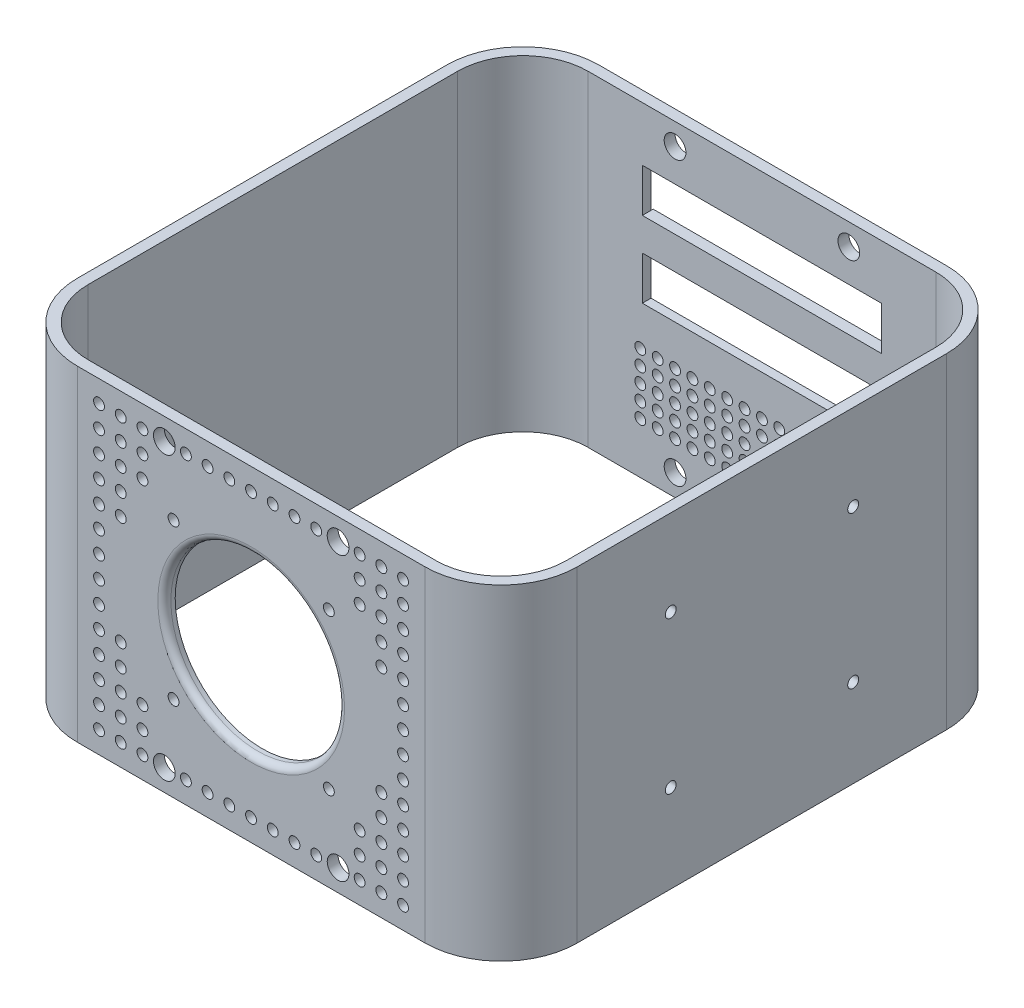
from build123d import *

# Parameters (mm, degrees)
BOSS_EXTRUDE1_DEPTH = 150
SKETCH11_R          = 2.5
CUT_EXTRUDE1_DEPTH  = 10
SKETCH12_R          = 5
CUT_EXTRUDE2_DEPTH  = 10
CUT_EXTRUDE3_START  = -10
SKETCH13_R          = 5
CUT_EXTRUDE3_DEPTH  = 10
SKETCH15_W          = 120.15
SKETCH15_H          = 65
CUT_EXTRUDE4_DEPTH  = 1
SKETCH15_3_W        = 110.15
SKETCH15_3_H        = 20
CUT_EXTRUDE5_DEPTH  = 10
SKETCH21_R          = 40
SKETCH21_R_2        = 2.5
CUT_EXTRUDE8_DEPTH  = 10
FILLET4_R           = 3
SKETCH27_R          = 2.5
CUT_EXTRUDE10_DEPTH = 10
SKETCH28_R          = 2.5
CUT_EXTRUDE13_DEPTH = 10


with BuildPart() as part:
    # Sketch1 → Boss-Extrude1 (new body)
    with BuildSketch(Plane(origin=(0, 0, 0), x_dir=(1, 0, 0), z_dir=(0, 1, 0))):
        with BuildLine():
            Line((-5, 30), (-5, 200.15))
            ThreePointArc((-5, 200.15), (5.251262658, 224.898737342), (30, 235.15))
            Line((30, 235.15), (190.15, 235.15))
            ThreePointArc((190.15, 235.15), (214.898737342, 224.898737342), (225.15, 200.15))
            Line((225.15, 200.15), (225.15, 30))
            ThreePointArc((225.15, 30), (214.898737342, 5.251262658), (190.15, -5))
            Line((190.15, -5), (30, -5))
            ThreePointArc((30, -5), (5.251262658, 5.251262658), (-5, 30))
        make_face()
        with BuildLine():
            Line((30, 0), (190.15, 0))
            ThreePointArc((190.15, 0), (211.363203436, 8.786796564), (220.15, 30))
            Line((220.15, 30), (220.15, 200.15))
            ThreePointArc((220.15, 200.15), (211.363203436, 221.363203436), (190.15, 230.15))
            Line((190.15, 230.15), (30, 230.15))
            ThreePointArc((30, 230.15), (8.786796564, 221.363203436), (0, 200.15))
            Line((0, 200.15), (0, 30))
            ThreePointArc((0, 30), (8.786796564, 8.786796564), (30, 0))
        make_face(mode=Mode.SUBTRACT)
    extrude(amount=BOSS_EXTRUDE1_DEPTH)

    # Sketch11 → Cut-Extrude1 (cut)
    with BuildSketch(Plane(origin=(225.15, 0, 0), x_dir=(0, 0, -1), z_dir=(1, 0, 0))):
        with Locations((73.075, 110.506208535)):
            Circle(SKETCH11_R)
        with Locations((73.075, 40.506208535)):
            Circle(SKETCH11_R)
        with Locations((157.075, 40.506208535)):
            Circle(SKETCH11_R)
        with Locations((157.075, 110.506208535)):
            Circle(SKETCH11_R)
    extrude(amount=-CUT_EXTRUDE1_DEPTH, mode=Mode.SUBTRACT)

    # Sketch12 → Cut-Extrude2 (cut)
    with BuildSketch(Plane(origin=(0, 0, -235.15), x_dir=(-1, 0, 0), z_dir=(0, 0, -1))):
        with Locations((-150.075, 140)):
            Circle(SKETCH12_R)
        with Locations((-70.075, 140)):
            Circle(SKETCH12_R)
        with Locations((-70.075, 10)):
            Circle(SKETCH12_R)
        with Locations((-150.075, 10)):
            Circle(SKETCH12_R)
    extrude(amount=-CUT_EXTRUDE2_DEPTH, mode=Mode.SUBTRACT)

    # Sketch13 → Cut-Extrude3 (cut)
    with BuildSketch(Plane.XY.offset(5).offset(CUT_EXTRUDE3_START)):
        with Locations((70.075, 140)):
            Circle(SKETCH13_R)
        with Locations((150.075, 140)):
            Circle(SKETCH13_R)
        with Locations((150.075, 10)):
            Circle(SKETCH13_R)
        with Locations((70.075, 10)):
            Circle(SKETCH13_R)
    extrude(amount=CUT_EXTRUDE3_DEPTH, mode=Mode.SUBTRACT)

    # Sketch15 → Cut-Extrude4 (cut)
    with BuildSketch(Plane(origin=(0, 0, -235.15), x_dir=(-1, 0, 0), z_dir=(0, 0, -1))):
        with Locations((-110.075, 97.5)):
            Rectangle(SKETCH15_W, SKETCH15_H)
        Polygon((-165.15, 105), (-165.15, 125), (-55, 125), (-55, 105), (-55, 90), (-55, 70), (-165.15, 70), (-165.15, 90), align=None, mode=Mode.SUBTRACT)
    extrude(amount=-CUT_EXTRUDE4_DEPTH, mode=Mode.SUBTRACT)

    # Sketch15_3 → Cut-Extrude5 (cut)
    with BuildSketch(Plane(origin=(0, 0, -235.15), x_dir=(-1, 0, 0), z_dir=(0, 0, -1))):
        with Locations((-110.075, 115)):
            Rectangle(SKETCH15_3_W, SKETCH15_3_H)
        with Locations((-110.075, 80)):
            Rectangle(SKETCH15_3_W, SKETCH15_3_H)
    extrude(amount=-CUT_EXTRUDE5_DEPTH, mode=Mode.SUBTRACT)

    # Sketch21 → Cut-Extrude8 (cut)
    with BuildSketch(Plane.XY.offset(5)):
        with Locations((110.075, 75)):
            Circle(SKETCH21_R)
        with Locations((74.325, 110.75)):
            Circle(SKETCH21_R_2)
        with Locations((145.825, 110.75)):
            Circle(SKETCH21_R_2)
        with Locations((145.825, 39.25)):
            Circle(SKETCH21_R_2)
        with Locations((74.325, 39.25)):
            Circle(SKETCH21_R_2)
    extrude(amount=-CUT_EXTRUDE8_DEPTH, mode=Mode.SUBTRACT)

    # Fillet4
    fillet4_edges = [part.edges().sort_by_distance(p)[0] for p in [
        (70.075, 75, 5),
    ]]
    fillet(fillet4_edges, radius=FILLET4_R)

    # Sketch27 → Cut-Extrude10 (cut)
    with BuildSketch(Plane(origin=(0, 0, -235.15), x_dir=(-1, 0, 0), z_dir=(0, 0, -1))):
        with Locations((-118.075, 37.5)):
            Circle(SKETCH27_R)
        with Locations((-126.075, 37.5)):
            Circle(SKETCH27_R)
        with Locations((-134.075, 37.5)):
            Circle(SKETCH27_R)
        with Locations((-142.075, 37.5)):
            Circle(SKETCH27_R)
        with Locations((-150.075, 37.5)):
            Circle(SKETCH27_R)
        with Locations((-158.075, 37.5)):
            Circle(SKETCH27_R)
        with Locations((-166.075, 37.5)):
            Circle(SKETCH27_R)
        with Locations((-118.075, 44.5)):
            Circle(SKETCH27_R)
        with Locations((-126.075, 44.5)):
            Circle(SKETCH27_R)
        with Locations((-134.075, 44.5)):
            Circle(SKETCH27_R)
        with Locations((-142.075, 44.5)):
            Circle(SKETCH27_R)
        with Locations((-150.075, 44.5)):
            Circle(SKETCH27_R)
        with Locations((-158.075, 44.5)):
            Circle(SKETCH27_R)
        with Locations((-166.075, 44.5)):
            Circle(SKETCH27_R)
        with Locations((-118.075, 51.5)):
            Circle(SKETCH27_R)
        with Locations((-126.075, 51.5)):
            Circle(SKETCH27_R)
        with Locations((-134.075, 51.5)):
            Circle(SKETCH27_R)
        with Locations((-142.075, 51.5)):
            Circle(SKETCH27_R)
        with Locations((-150.075, 51.5)):
            Circle(SKETCH27_R)
        with Locations((-158.075, 51.5)):
            Circle(SKETCH27_R)
        with Locations((-166.075, 51.5)):
            Circle(SKETCH27_R)
        with Locations((-110.075, 44.5)):
            Circle(SKETCH27_R)
        with Locations((-110.075, 51.5)):
            Circle(SKETCH27_R)
        with Locations((-110.075, 30.5)):
            Circle(SKETCH27_R)
        with Locations((-110.075, 23.5)):
            Circle(SKETCH27_R)
        with Locations((-166.075, 30.5)):
            Circle(SKETCH27_R)
        with Locations((-158.075, 30.5)):
            Circle(SKETCH27_R)
        with Locations((-150.075, 30.5)):
            Circle(SKETCH27_R)
        with Locations((-142.075, 30.5)):
            Circle(SKETCH27_R)
        with Locations((-134.075, 30.5)):
            Circle(SKETCH27_R)
        with Locations((-126.075, 30.5)):
            Circle(SKETCH27_R)
        with Locations((-118.075, 30.5)):
            Circle(SKETCH27_R)
        with Locations((-118.075, 23.5)):
            Circle(SKETCH27_R)
        with Locations((-126.075, 23.5)):
            Circle(SKETCH27_R)
        with Locations((-134.075, 23.5)):
            Circle(SKETCH27_R)
        with Locations((-142.075, 23.5)):
            Circle(SKETCH27_R)
        with Locations((-150.075, 23.5)):
            Circle(SKETCH27_R)
        with Locations((-158.075, 23.5)):
            Circle(SKETCH27_R)
        with Locations((-166.075, 23.5)):
            Circle(SKETCH27_R)
        with Locations((-102.075, 51.5)):
            Circle(SKETCH27_R)
        with Locations((-102.075, 44.5)):
            Circle(SKETCH27_R)
        with Locations((-102.075, 37.5)):
            Circle(SKETCH27_R)
        with Locations((-102.075, 30.5)):
            Circle(SKETCH27_R)
        with Locations((-102.075, 23.5)):
            Circle(SKETCH27_R)
        with Locations((-94.075, 51.5)):
            Circle(SKETCH27_R)
        with Locations((-94.075, 44.5)):
            Circle(SKETCH27_R)
        with Locations((-94.075, 37.5)):
            Circle(SKETCH27_R)
        with Locations((-94.075, 30.5)):
            Circle(SKETCH27_R)
        with Locations((-94.075, 23.5)):
            Circle(SKETCH27_R)
        with Locations((-86.075, 51.5)):
            Circle(SKETCH27_R)
        with Locations((-86.075, 44.5)):
            Circle(SKETCH27_R)
        with Locations((-86.075, 37.5)):
            Circle(SKETCH27_R)
        with Locations((-86.075, 30.5)):
            Circle(SKETCH27_R)
        with Locations((-86.075, 23.5)):
            Circle(SKETCH27_R)
        with Locations((-78.075, 51.5)):
            Circle(SKETCH27_R)
        with Locations((-78.075, 44.5)):
            Circle(SKETCH27_R)
        with Locations((-78.075, 37.5)):
            Circle(SKETCH27_R)
        with Locations((-78.075, 30.5)):
            Circle(SKETCH27_R)
        with Locations((-78.075, 23.5)):
            Circle(SKETCH27_R)
        with Locations((-70.075, 51.5)):
            Circle(SKETCH27_R)
        with Locations((-70.075, 44.5)):
            Circle(SKETCH27_R)
        with Locations((-70.075, 37.5)):
            Circle(SKETCH27_R)
        with Locations((-70.075, 30.5)):
            Circle(SKETCH27_R)
        with Locations((-70.075, 23.5)):
            Circle(SKETCH27_R)
        with Locations((-62.075, 51.5)):
            Circle(SKETCH27_R)
        with Locations((-62.075, 44.5)):
            Circle(SKETCH27_R)
        with Locations((-62.075, 37.5)):
            Circle(SKETCH27_R)
        with Locations((-62.075, 30.5)):
            Circle(SKETCH27_R)
        with Locations((-62.075, 23.5)):
            Circle(SKETCH27_R)
        with Locations((-54.075, 51.5)):
            Circle(SKETCH27_R)
        with Locations((-54.075, 44.5)):
            Circle(SKETCH27_R)
        with Locations((-54.075, 37.5)):
            Circle(SKETCH27_R)
        with Locations((-54.075, 30.5)):
            Circle(SKETCH27_R)
        with Locations((-54.075, 23.5)):
            Circle(SKETCH27_R)
    extrude(amount=-CUT_EXTRUDE10_DEPTH, mode=Mode.SUBTRACT)

    # Sketch28 → Cut-Extrude13 (cut)
    with BuildSketch(Plane.XY.offset(5)):
        with Locations((40, 140)):
            Circle(SKETCH28_R)
        with Locations((50, 140)):
            Circle(SKETCH28_R)
        with Locations((60, 140)):
            Circle(SKETCH28_R)
        with Locations((70, 140)):
            Circle(SKETCH28_R)
        with Locations((80, 140)):
            Circle(SKETCH28_R)
        with Locations((90, 140)):
            Circle(SKETCH28_R)
        with Locations((100, 140)):
            Circle(SKETCH28_R)
        with Locations((110, 140)):
            Circle(SKETCH28_R)
        with Locations((120, 140)):
            Circle(SKETCH28_R)
        with Locations((130, 140)):
            Circle(SKETCH28_R)
        with Locations((140, 140)):
            Circle(SKETCH28_R)
        with Locations((150, 140)):
            Circle(SKETCH28_R)
        with Locations((160, 140)):
            Circle(SKETCH28_R)
        with Locations((170, 140)):
            Circle(SKETCH28_R)
        with Locations((180, 140)):
            Circle(SKETCH28_R)
        with Locations((50, 130)):
            Circle(SKETCH28_R)
        with Locations((60, 130)):
            Circle(SKETCH28_R)
        with Locations((160, 130)):
            Circle(SKETCH28_R)
        with Locations((170, 130)):
            Circle(SKETCH28_R)
        with Locations((180, 130)):
            Circle(SKETCH28_R)
        with Locations((50, 120)):
            Circle(SKETCH28_R)
        with Locations((60, 120)):
            Circle(SKETCH28_R)
        with Locations((160, 120)):
            Circle(SKETCH28_R)
        with Locations((170, 120)):
            Circle(SKETCH28_R)
        with Locations((180, 120)):
            Circle(SKETCH28_R)
        with Locations((50, 110)):
            Circle(SKETCH28_R)
        with Locations((170, 110)):
            Circle(SKETCH28_R)
        with Locations((180, 110)):
            Circle(SKETCH28_R)
        with Locations((50, 100)):
            Circle(SKETCH28_R)
        with Locations((170, 100)):
            Circle(SKETCH28_R)
        with Locations((180, 100)):
            Circle(SKETCH28_R)
        with Locations((180, 90)):
            Circle(SKETCH28_R)
        with Locations((180, 80)):
            Circle(SKETCH28_R)
        with Locations((180, 70)):
            Circle(SKETCH28_R)
        with Locations((180, 60)):
            Circle(SKETCH28_R)
        with Locations((50, 50)):
            Circle(SKETCH28_R)
        with Locations((170, 50)):
            Circle(SKETCH28_R)
        with Locations((180, 50)):
            Circle(SKETCH28_R)
        with Locations((50, 40)):
            Circle(SKETCH28_R)
        with Locations((170, 40)):
            Circle(SKETCH28_R)
        with Locations((180, 40)):
            Circle(SKETCH28_R)
        with Locations((50, 30)):
            Circle(SKETCH28_R)
        with Locations((60, 30)):
            Circle(SKETCH28_R)
        with Locations((160, 30)):
            Circle(SKETCH28_R)
        with Locations((170, 30)):
            Circle(SKETCH28_R)
        with Locations((180, 30)):
            Circle(SKETCH28_R)
        with Locations((50, 20)):
            Circle(SKETCH28_R)
        with Locations((60, 20)):
            Circle(SKETCH28_R)
        with Locations((160, 20)):
            Circle(SKETCH28_R)
        with Locations((170, 20)):
            Circle(SKETCH28_R)
        with Locations((180, 20)):
            Circle(SKETCH28_R)
        with Locations((50, 10)):
            Circle(SKETCH28_R)
        with Locations((60, 10)):
            Circle(SKETCH28_R)
        with Locations((70, 10)):
            Circle(SKETCH28_R)
        with Locations((80, 10)):
            Circle(SKETCH28_R)
        with Locations((90, 10)):
            Circle(SKETCH28_R)
        with Locations((100, 10)):
            Circle(SKETCH28_R)
        with Locations((110, 10)):
            Circle(SKETCH28_R)
        with Locations((120, 10)):
            Circle(SKETCH28_R)
        with Locations((130, 10)):
            Circle(SKETCH28_R)
        with Locations((140, 10)):
            Circle(SKETCH28_R)
        with Locations((150, 10)):
            Circle(SKETCH28_R)
        with Locations((160, 10)):
            Circle(SKETCH28_R)
        with Locations((170, 10)):
            Circle(SKETCH28_R)
        with Locations((180, 10)):
            Circle(SKETCH28_R)
        with Locations((40, 130)):
            Circle(SKETCH28_R)
        with Locations((40, 120)):
            Circle(SKETCH28_R)
        with Locations((40, 110)):
            Circle(SKETCH28_R)
        with Locations((40, 100)):
            Circle(SKETCH28_R)
        with Locations((40, 90)):
            Circle(SKETCH28_R)
        with Locations((40, 80)):
            Circle(SKETCH28_R)
        with Locations((40, 70)):
            Circle(SKETCH28_R)
        with Locations((40, 60)):
            Circle(SKETCH28_R)
        with Locations((40, 50)):
            Circle(SKETCH28_R)
        with Locations((40, 40)):
            Circle(SKETCH28_R)
        with Locations((40, 30)):
            Circle(SKETCH28_R)
        with Locations((40, 20)):
            Circle(SKETCH28_R)
        with Locations((40, 10)):
            Circle(SKETCH28_R)
    extrude(amount=-CUT_EXTRUDE13_DEPTH, mode=Mode.SUBTRACT)


solid = part.part
